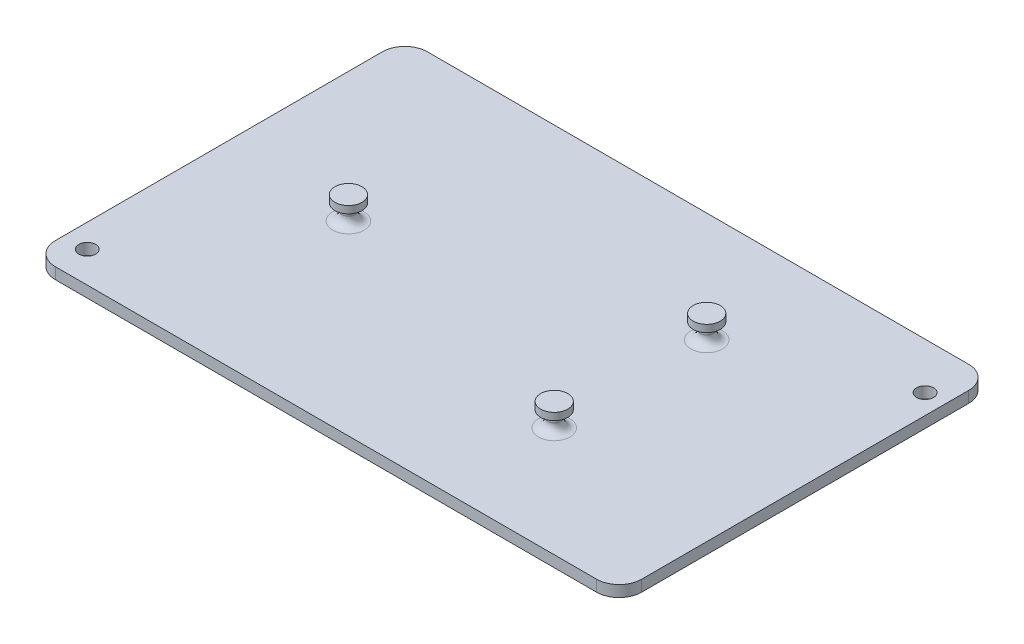
from build123d import *

# Parameters (mm, degrees)
SKETCH1_W           = 165.1
SKETCH1_H           = 104.775
BOSS_EXTRUDE1_DEPTH = 3.175
FILLET1_R           = 2.54
FILLET2_R           = 0.508
FILLET3_R           = 6.35
SKETCH4_R           = 2.38125
CUT_EXTRUDE1_DEPTH  = 4.175


with BuildPart() as part:
    # Sketch1 → Boss-Extrude1 (new body)
    with BuildSketch(Plane(origin=(0, 0, 0), x_dir=(1, 0, 0), z_dir=(0, 1, 0))):
        Rectangle(SKETCH1_W, SKETCH1_H)
    extrude(amount=BOSS_EXTRUDE1_DEPTH)

    # Sketch2 → Revolve1 (revolve)
    with BuildSketch(Plane.XY):
        Polygon((-46.0502, 3.175), (-46.0502, 9.652), (-42.2402, 9.652), (-42.2402, 7.62), (-44.1452, 7.62), (-44.1452, 3.175), align=None)
    revolve(axis=Axis((-46.0502, 3.175, 0), (0, 1, 0)))

    # Sketch3 → Revolve2 (revolve)
    with BuildSketch(Plane(origin=(33.3502, 0, 0), x_dir=(0, 0, -1), z_dir=(1, 0, 0))):
        Polygon((-21.463, 3.175), (-21.463, 9.652), (-17.653, 9.652), (-17.653, 7.62), (-19.558, 7.62), (-19.558, 3.175), align=None)
    revolve2 = revolve(axis=Axis((33.3502, 3.175, 21.463), (0, 1, 0)))

    # Mirror1: Revolve2 across plane
    add(revolve2.mirror(Plane.XY))

    # Fillet1
    fillet1_edges = [part.edges().sort_by_distance(p)[0] for p in [
        (-47.9552, 3.175, 0),
        (33.3502, 3.175, 23.368),
        (33.3502, 3.175, -23.368),
    ]]
    fillet(fillet1_edges, radius=FILLET1_R)

    # Fillet2
    fillet2_edges = [part.edges().sort_by_distance(p)[0] for p in [
        (-47.9552, 7.62, 0),
        (33.3502, 7.62, 23.368),
        (33.3502, 7.62, -23.368),
    ]]
    fillet(fillet2_edges, radius=FILLET2_R)

    # Fillet3
    fillet3_edges = [part.edges().sort_by_distance(p)[0] for p in [
        (82.55, 1.5875, 52.3875),
        (-82.55, 1.5875, 52.3875),
        (-82.55, 1.5875, -52.3875),
        (82.55, 1.5875, -52.3875),
    ]]
    fillet(fillet3_edges, radius=FILLET3_R)

    # Sketch4 → Cut-Extrude1 (cut, through all)
    with BuildSketch(Plane(origin=(0, 3.175, 0), x_dir=(1, 0, 0), z_dir=(0, 1, 0))):
        with Locations((-75.9329952, -43.643499962)):
            Circle(SKETCH4_R)
        with Locations((76.96699999, 39.3344908)):
            Circle(SKETCH4_R)
    extrude(amount=-CUT_EXTRUDE1_DEPTH, mode=Mode.SUBTRACT)


solid = part.part
